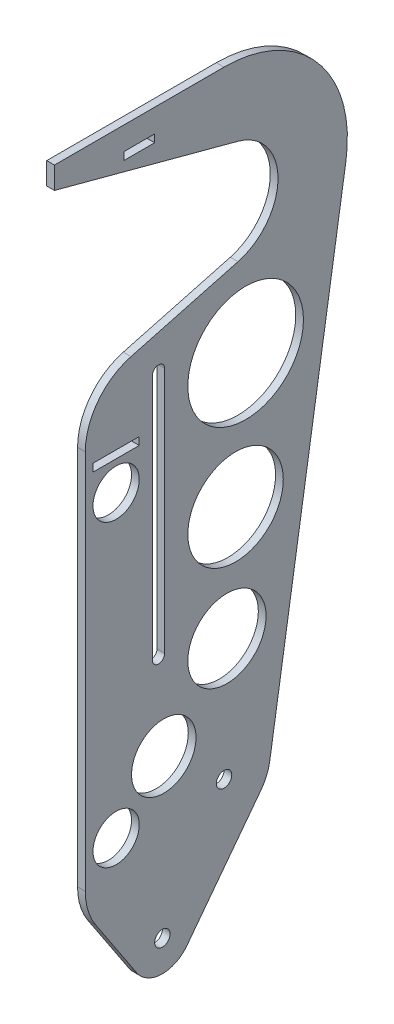
from build123d import *

# Parameters (mm, degrees)
SKETCH1_R           = 3.175
BOSS_EXTRUDE1_DEPTH = 3.175
SKETCH2_W           = 19.05
SKETCH2_H           = 3.175
SKETCH2_W_2         = 12.7
CUT_EXTRUDE1_DEPTH  = 4.175
SKETCH3_R           = 23.810582085
SKETCH3_R_2         = 19.657709657
SKETCH3_R_3         = 16.108424526
SKETCH3_R_4         = 13.273253647
CUT_EXTRUDE2_DEPTH  = 4.175
SKETCH4_R           = 9.525
CUT_EXTRUDE3_DEPTH  = 4.175


with BuildPart() as part:
    # Sketch1 → Boss-Extrude1 (new body)
    with BuildSketch(Plane(origin=(0, 0, 0), x_dir=(0, 0, -1), z_dir=(1, 0, 0))):
        with BuildLine():
            Line((-69.85, 244.925264201), (5.752253277, 224.667701489))
            ThreePointArc((5.752253277, 224.667701489), (22.225, 203.2), (5.752253277, 181.732298511))
            Line((5.752253277, 181.732298511), (-38.324003746, 169.922101036))
            ThreePointArc((-38.324003746, 169.922101036), (-51.901174843, 160.850125345), (-57.15, 145.387585048))
            Line((-57.15, 145.387585048), (-57.15, -11.402464944))
            ThreePointArc((-57.15, -11.402464944), (-56.071518944, -18.725286548), (-52.927660139, -25.426255839))
            Line((-52.927660139, -25.426255839), (-35.988830069, -51.00598596))
            ThreePointArc((-35.988830069, -51.00598596), (-25.80648624, -56.687583685), (-15.281491626, -51.66910115))
            Line((-15.281491626, -51.66910115), (15.17776256, -11.512515957))
            ThreePointArc((15.17776256, -11.512515957), (17.524552025, -7.46944284), (18.816019124, -2.9765625))
            Line((18.816019124, -2.9765625), (50.176050998, 195.2625))
            ThreePointArc((50.176050998, 195.2625), (38.625542067, 236.195567884), (0, 254))
            Line((0, 254), (-69.85, 254))
            Line((-69.85, 254), (-69.85, 244.925264201))
        make_face()
        Circle(SKETCH1_R, mode=Mode.SUBTRACT)
        with Locations((-25.4, -43.994090512)):
            Circle(SKETCH1_R, mode=Mode.SUBTRACT)
        with BuildLine():
            Line((-24.4475, 158.75), (-24.4475, 57.15))
            ThreePointArc((-24.4475, 57.15), (-26.9875, 54.61), (-29.5275, 57.15))
            Line((-29.5275, 57.15), (-29.5275, 158.75))
            ThreePointArc((-29.5275, 158.75), (-26.9875, 161.29), (-24.4475, 158.75))
        make_face(mode=Mode.SUBTRACT)
    extrude(amount=BOSS_EXTRUDE1_DEPTH)

    # Sketch2 → Cut-Extrude1 (cut, through all)
    with BuildSketch(Plane.ZY):
        with Locations((44.45, 138.1125)):
            Rectangle(SKETCH2_W, SKETCH2_H)
        with Locations((34.925, 242.8875)):
            Rectangle(SKETCH2_W_2, SKETCH2_H)
    extrude(amount=-CUT_EXTRUDE1_DEPTH, mode=Mode.SUBTRACT)

    # Sketch3 → Cut-Extrude2 (cut, through all)
    with BuildSketch(Plane(origin=(3.175, 0, 0), x_dir=(0, 0, -1), z_dir=(1, 0, 0))):
        with Locations((8.888082085, 147.612778574)):
            Circle(SKETCH3_R)
        with Locations((4.735209657, 94.782459436)):
            Circle(SKETCH3_R_2)
        with Locations((1.185924526, 49.630611073)):
            Circle(SKETCH3_R_3)
        with Locations((-24.826746353, 20.698439358)):
            Circle(SKETCH3_R_4)
    extrude(amount=-CUT_EXTRUDE2_DEPTH, mode=Mode.SUBTRACT)

    # Sketch4 → Cut-Extrude3 (cut, through all)
    with BuildSketch(Plane(origin=(3.175, 0, 0), x_dir=(0, 0, -1), z_dir=(1, 0, 0))):
        with Locations((-44.45, 124.46)):
            Circle(SKETCH4_R)
        with Locations((-44.45, 1.27)):
            Circle(SKETCH4_R)
    extrude(amount=-CUT_EXTRUDE3_DEPTH, mode=Mode.SUBTRACT)


solid = part.part
